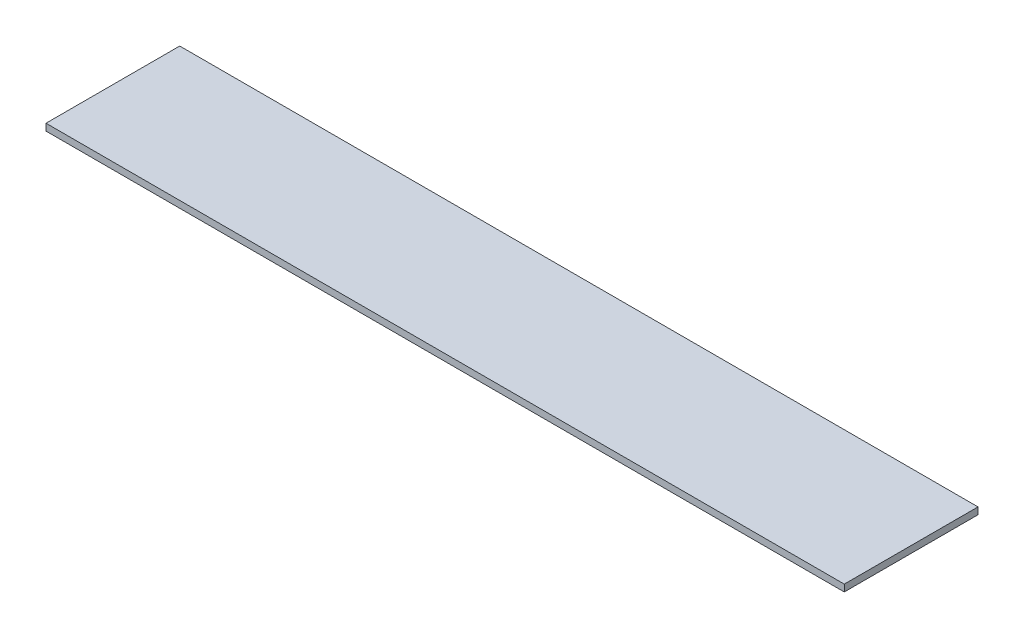
from build123d import *

# Parameters (mm, degrees)
SKETCH1_W           = 1667.887484894
SKETCH1_H           = 279.4
BOSS_EXTRUDE1_DEPTH = 14.2875


with BuildPart() as part:
    # Sketch1 → Boss-Extrude1 (new body)
    with BuildSketch(Plane(origin=(0, 0, 0), x_dir=(1, 0, 0), z_dir=(0, 1, 0))):
        with Locations((-61.773610552, 270.653270093)):
            Rectangle(SKETCH1_W, SKETCH1_H)
    extrude(amount=BOSS_EXTRUDE1_DEPTH)


solid = part.part
